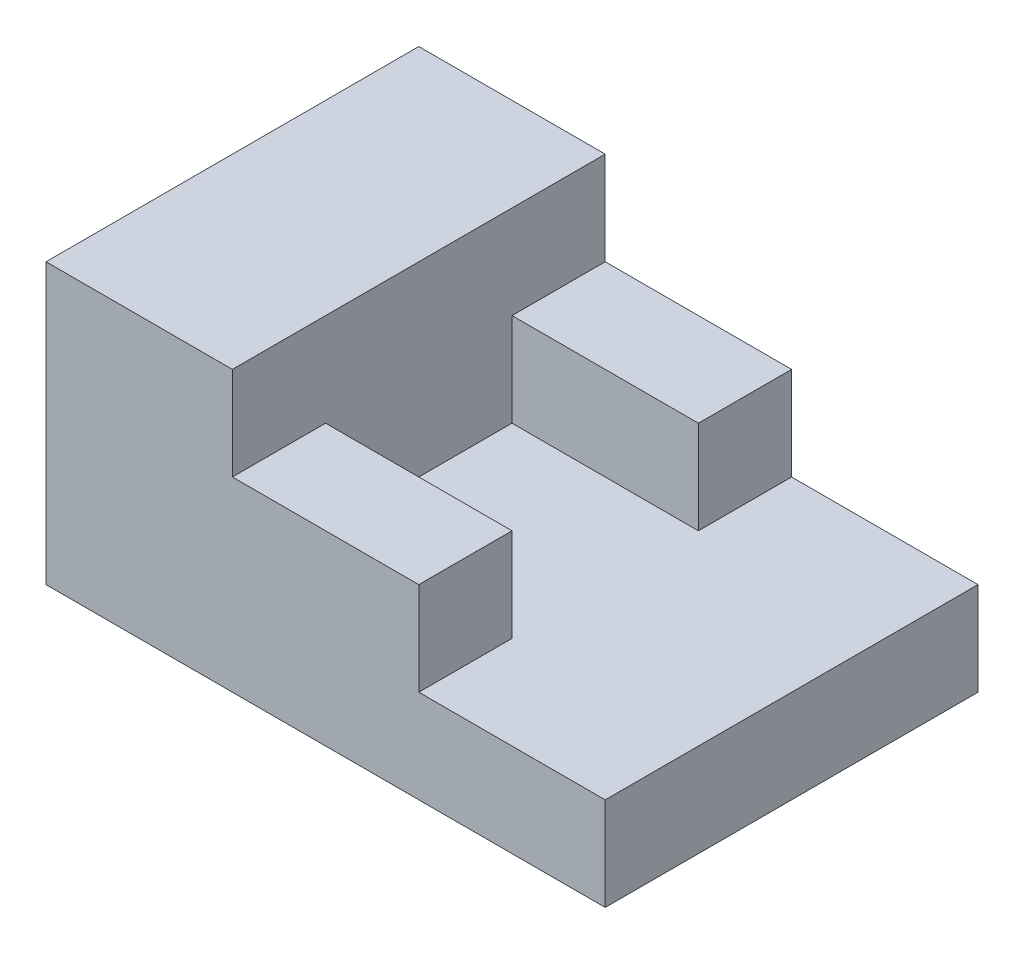
from build123d import *

# Parameters (mm, degrees)
SKETCH_1_W      = 30
SKETCH_1_H      = 20
EXTRUDE_1_DEPTH = 5
EXTRUDE_2_DEPTH = 10
EXTRUDE_3_DEPTH = 15


with BuildPart() as part:
    # 草圖1 → 填料-伸長1 (new body)
    with BuildSketch(Plane(origin=(0, 0, 0), x_dir=(1, 0, 0), z_dir=(0, 1, 0))):
        Rectangle(SKETCH_1_W, SKETCH_1_H)
    extrude(amount=EXTRUDE_1_DEPTH)

    # 草圖1<3> → 填料-伸長2 (add)
    with BuildSketch(Plane(origin=(0, 0, 0), x_dir=(1, 0, 0), z_dir=(0, 1, 0))):
        Polygon((5, 10), (-15, 10), (-15, -10), (5, -10), (5, -5), (-5, -5), (-5, 5), (5, 5), align=None)
    extrude(amount=EXTRUDE_2_DEPTH)

    # 草圖1<4> → 填料-伸長3 (add)
    with BuildSketch(Plane(origin=(0, 0, 0), x_dir=(1, 0, 0), z_dir=(0, 1, 0))):
        Polygon((-5, 5), (-5, 10), (-15, 10), (-15, -10), (-5, -10), (-5, -5), align=None)
    extrude(amount=EXTRUDE_3_DEPTH)


solid = part.part
